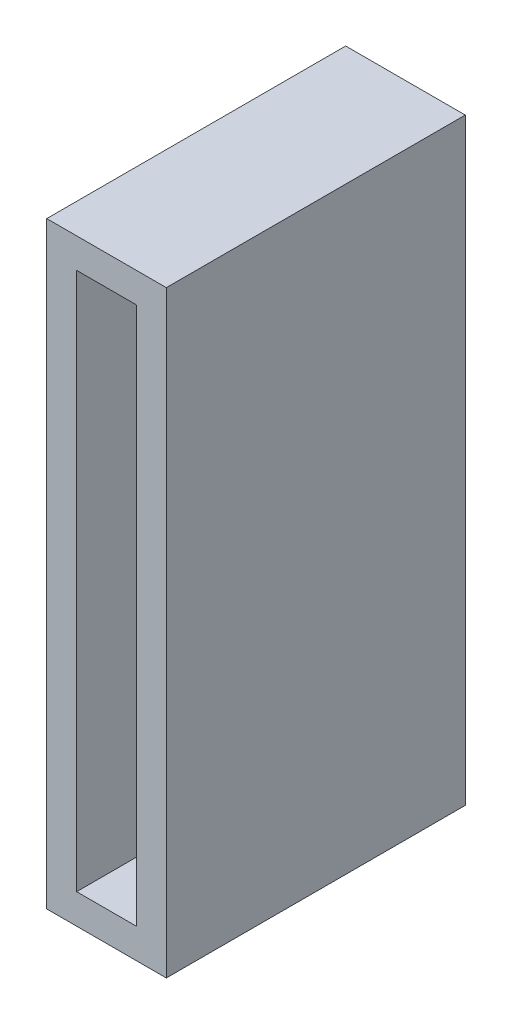
from build123d import *

# Parameters (mm, degrees)
ESQUISSE1_W        = 40
ESQUISSE1_H        = 200
ESQUISSE1_W_2      = 20
ESQUISSE1_H_2      = 180
BOSS_EXTRU_2_DEPTH = 100


with BuildPart() as part:
    # Esquisse1 → Boss.-Extru.2 (new body)
    with BuildSketch(Plane.XY):
        with Locations((20, 100)):
            Rectangle(ESQUISSE1_W, ESQUISSE1_H)
        with Locations((20, 100)):
            Rectangle(ESQUISSE1_W_2, ESQUISSE1_H_2, mode=Mode.SUBTRACT)
    extrude(amount=BOSS_EXTRU_2_DEPTH)


solid = part.part
